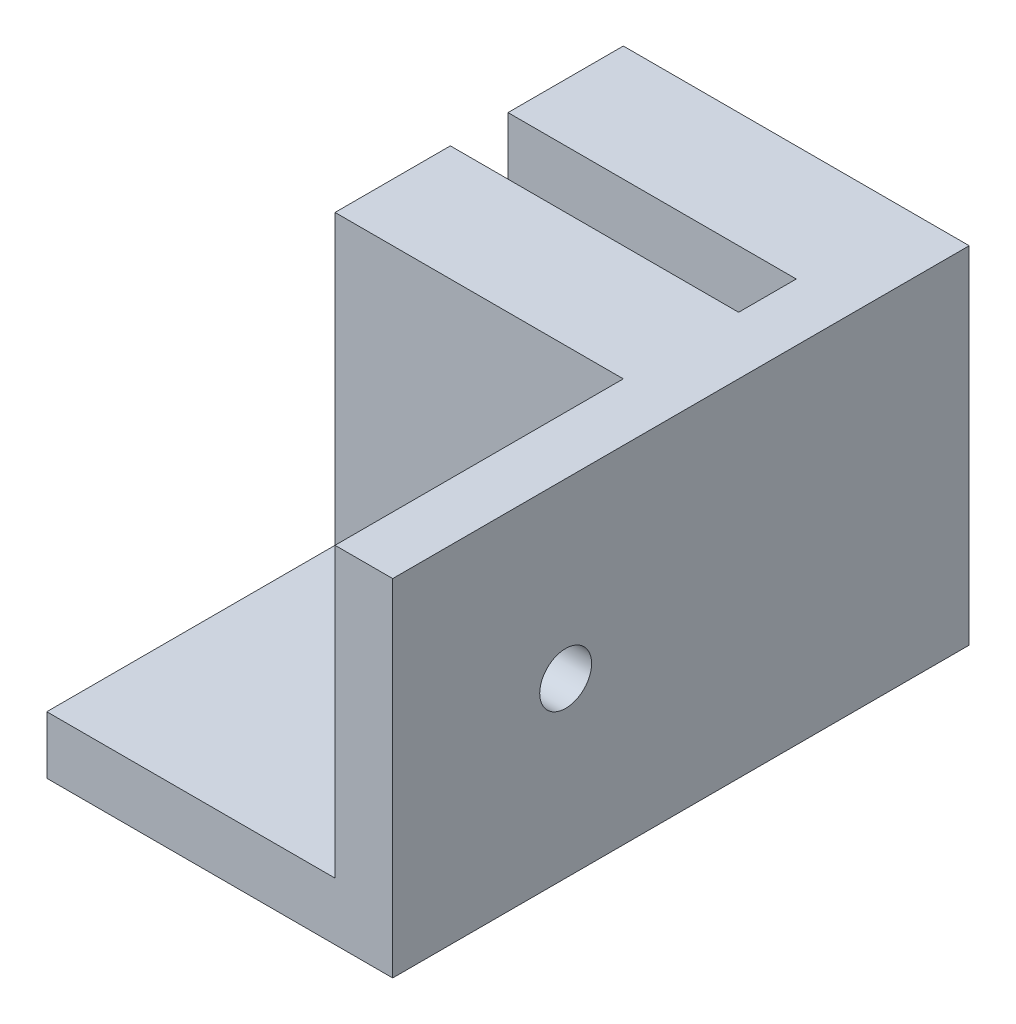
from build123d import *

# Parameters (mm, degrees)
ESBO_O1_W                         = 30
ESBO_O1_H                         = 30
RESSALTO_EXTRUS_O1_DEPTH          = 50
ESBO_O2_W                         = 25
ESBO_O2_H                         = 5
CORTE_EXTRUS_O1_DEPTH             = 31
ESBO_O3_W                         = 25
ESBO_O3_H                         = 25
CORTE_EXTRUS_O2_DEPTH             = 25
FURO_COM_FOLGA_DE_M41_D           = 4.5
FURO_COM_FOLGA_DE_M41_ON_FACE_2_D = 4.5


with BuildPart() as part:
    # Esboço1 → Ressalto-extrusão1 (new body)
    with BuildSketch(Plane.XY):
        with Locations((-15, 15)):
            Rectangle(ESBO_O1_W, ESBO_O1_H)
    extrude(amount=RESSALTO_EXTRUS_O1_DEPTH)

    # Esboço2 → Corte-extrusão1 (cut, through all)
    with BuildSketch(Plane(origin=(0, 30, 0), x_dir=(1, 0, 0), z_dir=(0, 1, 0))):
        with Locations((-17.5, -12.5)):
            Rectangle(ESBO_O2_W, ESBO_O2_H)
    extrude(amount=-CORTE_EXTRUS_O1_DEPTH, mode=Mode.SUBTRACT)

    # Esboço3 → Corte-extrusão2 (cut)
    with BuildSketch(Plane(origin=(0, 30, 0), x_dir=(1, 0, 0), z_dir=(0, 1, 0))):
        with Locations((-17.5, -37.5)):
            Rectangle(ESBO_O3_W, ESBO_O3_H)
    extrude(amount=-CORTE_EXTRUS_O2_DEPTH, mode=Mode.SUBTRACT)

    # Furo com folga de M41 (through all)
    with Locations(Plane(origin=(-15, 5, 35), x_dir=(0, 0, 1), z_dir=(0, 1, 0))):
        with Locations((0, 0)):
            Hole(FURO_COM_FOLGA_DE_M41_D / 2)

    # Furo com folga de M41 on face 2 (through all)
    with Locations(Plane(origin=(-5, 15, 35), x_dir=(0, 0, -1), z_dir=(-1, 0, 0))):
        with Locations((0, 0)):
            Hole(FURO_COM_FOLGA_DE_M41_ON_FACE_2_D / 2)


solid = part.part
